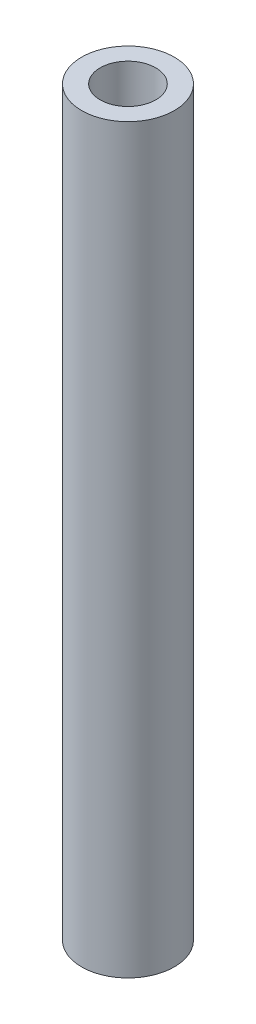
from build123d import *

# Parameters (mm, degrees)
SKETCH1_R           = 2.5
SKETCH1_R_2         = 1.5
BOSS_EXTRUDE1_DEPTH = 40


with BuildPart() as part:
    # Sketch1 → Boss-Extrude1 (new body)
    with BuildSketch(Plane(origin=(0, 0, 0), x_dir=(1, 0, 0), z_dir=(0, 1, 0))):
        Circle(SKETCH1_R)
        Circle(SKETCH1_R_2, mode=Mode.SUBTRACT)
    extrude(amount=BOSS_EXTRUDE1_DEPTH)


solid = part.part
